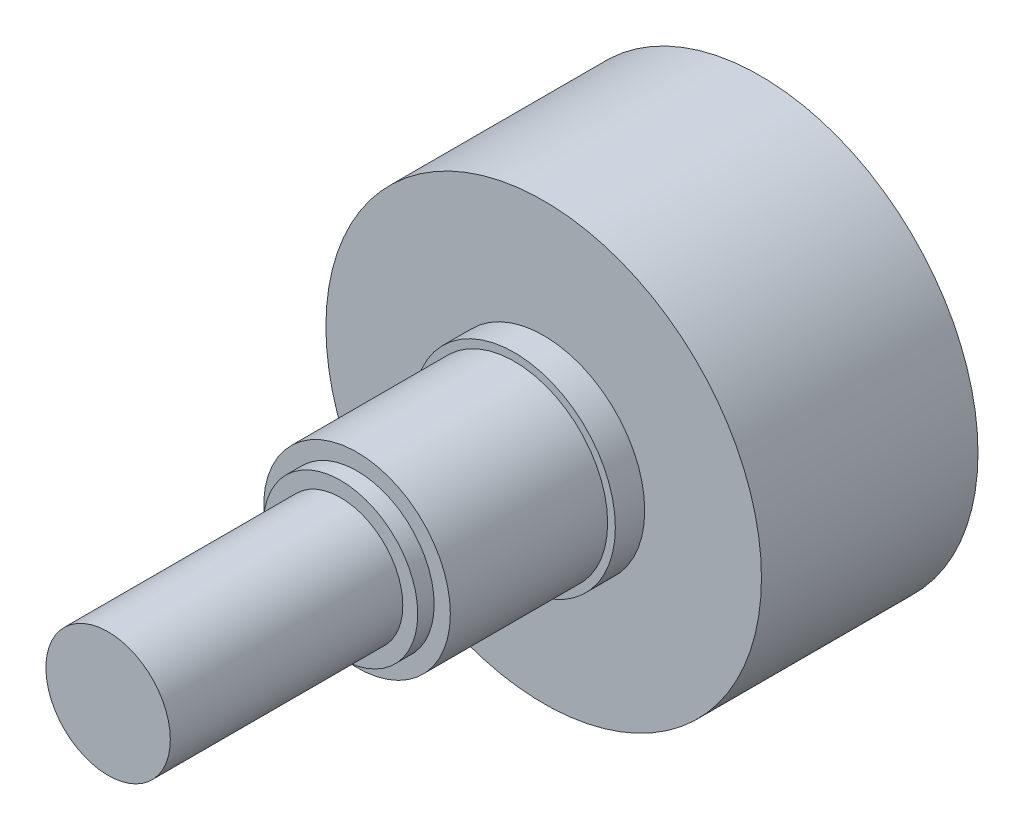
from build123d import *

# Parameters (mm, degrees)
SKETCH1_R           = 11.1125
BOSS_EXTRUDE1_DEPTH = 11.049
SKETCH2_R           = 5.1562
BOSS_EXTRUDE2_DEPTH = 1.4986
SKETCH3_R           = 4.7625
BOSS_EXTRUDE5_DEPTH = 9.525
SKETCH4_R           = 3.937
BOSS_EXTRUDE6_DEPTH = 0.8382
SKETCH5_R           = 3.175
BOSS_EXTRUDE7_DEPTH = 22.225


with BuildPart() as part:
    # Sketch1 → Boss-Extrude1 (new body)
    with BuildSketch(Plane.XY):
        Circle(SKETCH1_R)
    extrude(amount=BOSS_EXTRUDE1_DEPTH)

    # Sketch2 → Boss-Extrude2 (add)
    with BuildSketch(Plane.XY.offset(11.049)):
        Circle(SKETCH2_R)
    extrude(amount=BOSS_EXTRUDE2_DEPTH)

    # Sketch3 → Boss-Extrude5 (add)
    with BuildSketch(Plane.XY.offset(11.049)):
        Circle(SKETCH3_R)
    extrude(amount=BOSS_EXTRUDE5_DEPTH)

    # Sketch4 → Boss-Extrude6 (add)
    with BuildSketch(Plane.XY.offset(20.574)):
        Circle(SKETCH4_R)
    extrude(amount=BOSS_EXTRUDE6_DEPTH)

    # Sketch5 → Boss-Extrude7 (add)
    with BuildSketch(Plane.XY.offset(11.049)):
        Circle(SKETCH5_R)
    extrude(amount=BOSS_EXTRUDE7_DEPTH)


solid = part.part
